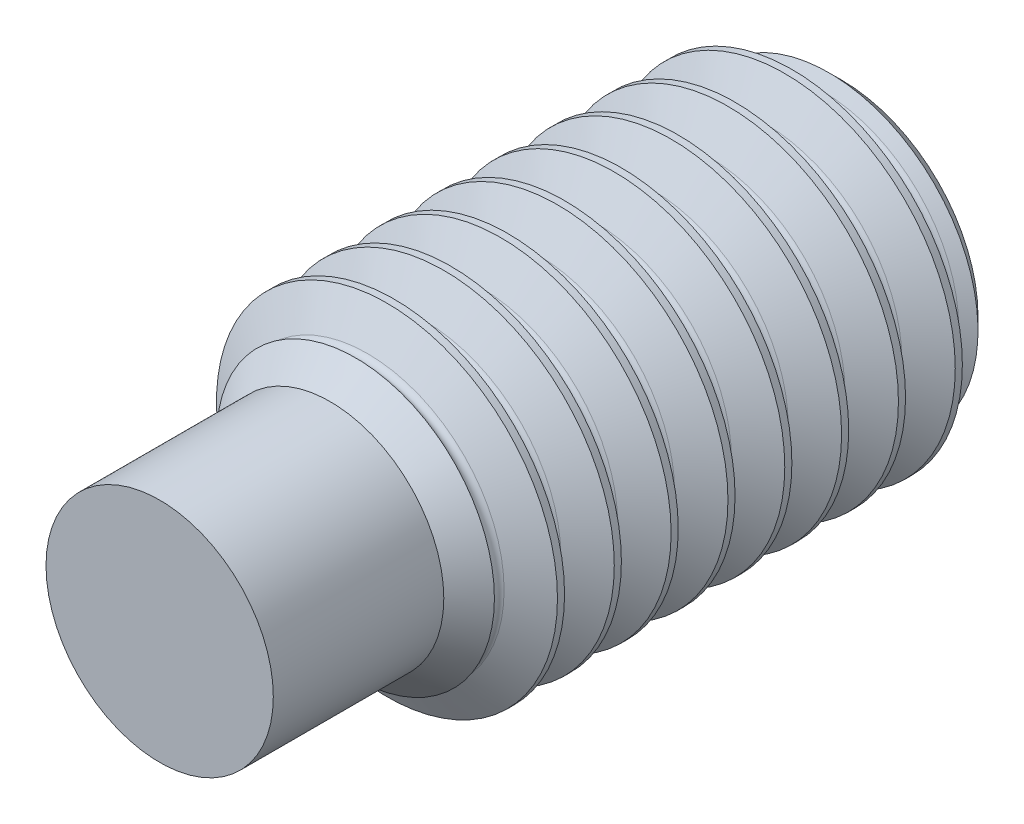
from build123d import *

# Parameters (mm, degrees)
SKETCH5_W           = 6
SKETCH5_H           = 1.5
THREAD_SIMPLE_COUNT = 13
THREAD_SIMPLE_PITCH = 0.5
CUT_HEAD_KEY_DEPTH  = 1.5


with BuildPart() as part:
    # Sketch5 → body (revolve)
    with BuildSketch(Plane(origin=(0, 0, 0), x_dir=(0, 0, -1), z_dir=(1, 0, 0))):
        with Locations((-3, 0.75)):
            Rectangle(SKETCH5_W, SKETCH5_H)
    revolve(axis=Axis((0, 0, 6), (0, 0, -1)))

    # Sketch13 → cut-chamfer-end (revolve, cut)
    with BuildSketch(Plane(origin=(0, 0, 0), x_dir=(0, 0, -1), z_dir=(1, 0, 0))):
        Polygon((0, -1.5), (-0.3, -1.5), (0, -1.2), align=None)
    revolve(axis=Axis((0, 0, 6), (0, 0, -1)), mode=Mode.SUBTRACT)

    # Sketch8 → thread-single (revolve, cut)
    with BuildSketch(Plane(origin=(0, 0, 0), x_dir=(0, 0, -1), z_dir=(1, 0, 0))):
        with BuildLine():
            Line((-0.4375, -1.5), (0, -1.5))
            Line((0, -1.5), (-0.171875, -1.202303767))
            ThreePointArc((-0.171875, -1.202303767), (-0.21875, -1.175240474), (-0.265625, -1.202303767))
            Line((-0.265625, -1.202303767), (-0.4375, -1.5))
        make_face()
    thread_single = revolve(axis=Axis((0, 0, 6), (0, 0, -1)), mode=Mode.SUBTRACT)

    # thread-simple: thread-single ×13
    with Locations(*[(0, 0, i * THREAD_SIMPLE_PITCH) for i in range(1, THREAD_SIMPLE_COUNT)]):
        add(thread_single, mode=Mode.SUBTRACT)

    # Sketch25 → cut-head-key (cut)
    with BuildSketch(Plane.XY):
        Polygon((0.433012702, 0.75), (-0.433012702, 0.75), (-0.866025404, 0), (-0.433012702, -0.75), (0.433012702, -0.75), (0.866025404, 0), align=None)
    extrude(amount=CUT_HEAD_KEY_DEPTH, mode=Mode.SUBTRACT)

    # Sketch26 → cut-top-body (revolve, cut)
    with BuildSketch(Plane(origin=(0, 0, 0), x_dir=(0, 0, -1), z_dir=(1, 0, 0))):
        Polygon((-6, -1.5), (-6, -1), (-4.5, -1), (-4, -1.5), align=None)
    revolve(axis=Axis((0, 0, 6), (0, 0, -1)), mode=Mode.SUBTRACT)


solid = part.part
